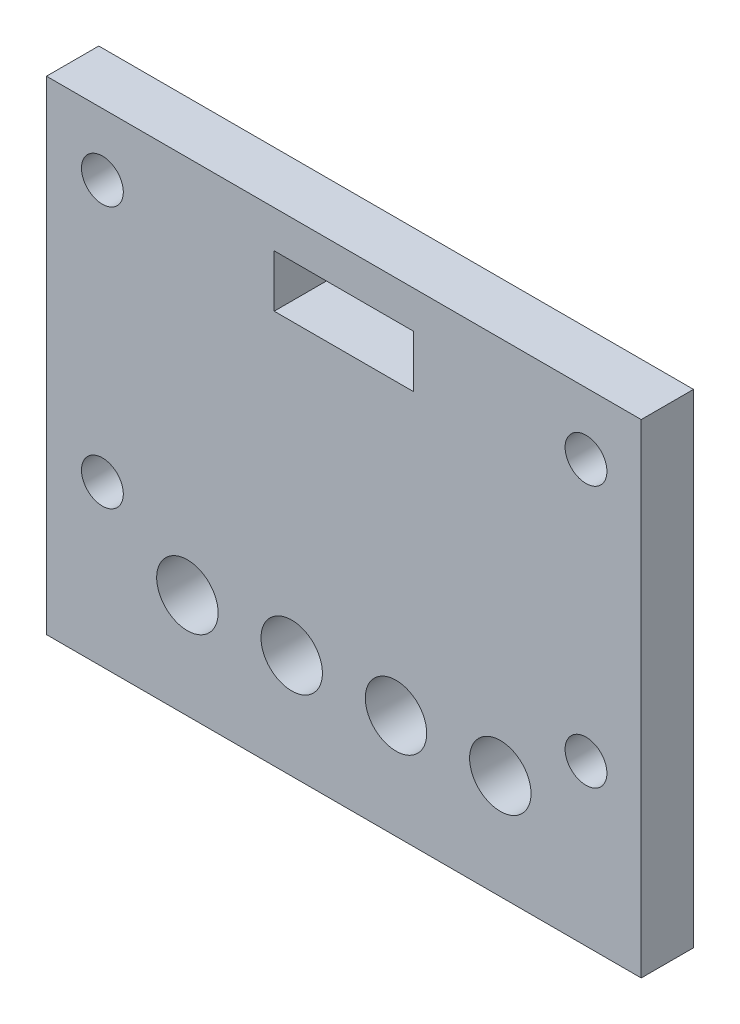
from build123d import *

# Parameters (mm, degrees)
SKETCH1_W               = 45.5
SKETCH1_H               = 37
SKETCH1_W_2             = 10.66
SKETCH1_H_2             = 4
BOSS_EXTRUDE1_DEPTH     = 4
SKETCH3_R               = 1.6
CUT_EXTRUDE5_DEPTH      = 10
CUT_EXTRUDE5_DEPTH_BACK = 1
SKETCH4_R               = 2.35
LEGO_GATEN_DEPTH        = 10


with BuildPart() as part:
    # Sketch1 → Boss-Extrude1 (new body)
    with BuildSketch(Plane.XY):
        with Locations((22.75, 18.5)):
            Rectangle(SKETCH1_W, SKETCH1_H)
        with Locations((22.75, 32.14)):
            Rectangle(SKETCH1_W_2, SKETCH1_H_2, mode=Mode.SUBTRACT)
    extrude(amount=BOSS_EXTRUDE1_DEPTH)

    # Sketch3 → Cut-Extrude5 (cut, two sides)
    with BuildSketch(Plane.XY) as cut_extrude5_sk:
        with Locations((41.27584891, 32.252592082)):
            Circle(SKETCH3_R)
        with Locations((41.27584891, 12.252592082)):
            Circle(SKETCH3_R)
        with Locations((4.27584891, 12.252592082)):
            Circle(SKETCH3_R)
        with Locations((4.27584891, 32.252592082)):
            Circle(SKETCH3_R)
    extrude(amount=CUT_EXTRUDE5_DEPTH, mode=Mode.SUBTRACT)
    extrude(cut_extrude5_sk.sketch, amount=-CUT_EXTRUDE5_DEPTH_BACK, mode=Mode.SUBTRACT)

    # Sketch4 → Lego gaten (cut)
    with BuildSketch(Plane.XY.offset(4)):
        with Locations((10.78, 8)):
            Circle(SKETCH4_R)
        with Locations((18.76, 8)):
            Circle(SKETCH4_R)
        with Locations((26.74, 8)):
            Circle(SKETCH4_R)
        with Locations((34.72, 8)):
            Circle(SKETCH4_R)
    extrude(amount=-LEGO_GATEN_DEPTH, mode=Mode.SUBTRACT)


solid = part.part
